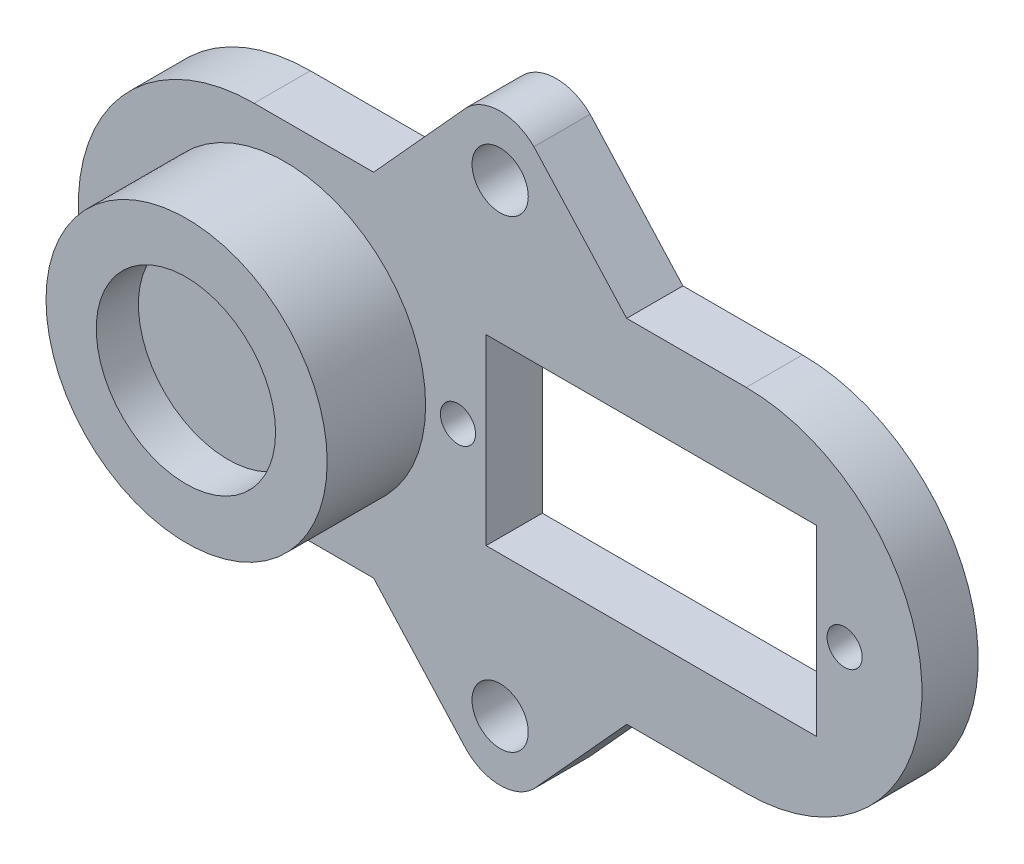
from build123d import *

# Parameters (mm, degrees)
SKETCH1_R           = 2
SKETCH1_R_2         = 1.25
SKETCH1_W           = 23.5
SKETCH1_H           = 13
BOSS_EXTRUDE1_DEPTH = 4
SKETCH3_R           = 10
BOSS_EXTRUDE2_DEPTH = 7
SKETCH4_R           = 6.377506195
CUT_EXTRUDE1_DEPTH  = 3


with BuildPart() as part:
    # Sketch1 → Boss-Extrude1 (new body)
    with BuildSketch(Plane.XY):
        with BuildLine():
            Line((-9, 12.5), (-2.401010284, 19.772380391))
            ThreePointArc((-2.401010284, 19.772380391), (0, 20.766911414), (2.401010284, 19.772380391))
            Line((2.401010284, 19.772380391), (9, 12.5))
            Line((9, 12.5), (17.5, 12.5))
            ThreePointArc((17.5, 12.5), (30, 0), (17.5, -12.5))
            Line((17.5, -12.5), (9, -12.5))
            Line((9, -12.5), (2.401010284, -19.772380391))
            ThreePointArc((2.401010284, -19.772380391), (0, -20.766911414), (-2.401010284, -19.772380391))
            Line((-2.401010284, -19.772380391), (-9, -12.5))
            Line((-9, -12.5), (-17.5, -12.5))
            ThreePointArc((-17.5, -12.5), (-30, 0), (-17.5, 12.5))
            Line((-17.5, 12.5), (-9, 12.5))
        make_face()
        with Locations((0, 16.5)):
            Circle(SKETCH1_R, mode=Mode.SUBTRACT)
        with Locations((0, -16.5)):
            Circle(SKETCH1_R, mode=Mode.SUBTRACT)
        with Locations((-3, 0)):
            Circle(SKETCH1_R_2, mode=Mode.SUBTRACT)
        with Locations((24.5, 0)):
            Circle(SKETCH1_R_2, mode=Mode.SUBTRACT)
        with Locations((10.75, 0)):
            Rectangle(SKETCH1_W, SKETCH1_H, mode=Mode.SUBTRACT)
    extrude(amount=BOSS_EXTRUDE1_DEPTH)

    # Sketch3 → Boss-Extrude2 (add)
    with BuildSketch(Plane.XY.offset(4)):
        with Locations((-15.3, 0)):
            Circle(SKETCH3_R)
    extrude(amount=BOSS_EXTRUDE2_DEPTH)

    # Sketch4 → Cut-Extrude1 (cut)
    with BuildSketch(Plane.XY.offset(11)):
        with Locations((-15.35, 0)):
            Circle(SKETCH4_R)
    extrude(amount=-CUT_EXTRUDE1_DEPTH, mode=Mode.SUBTRACT)


solid = part.part
